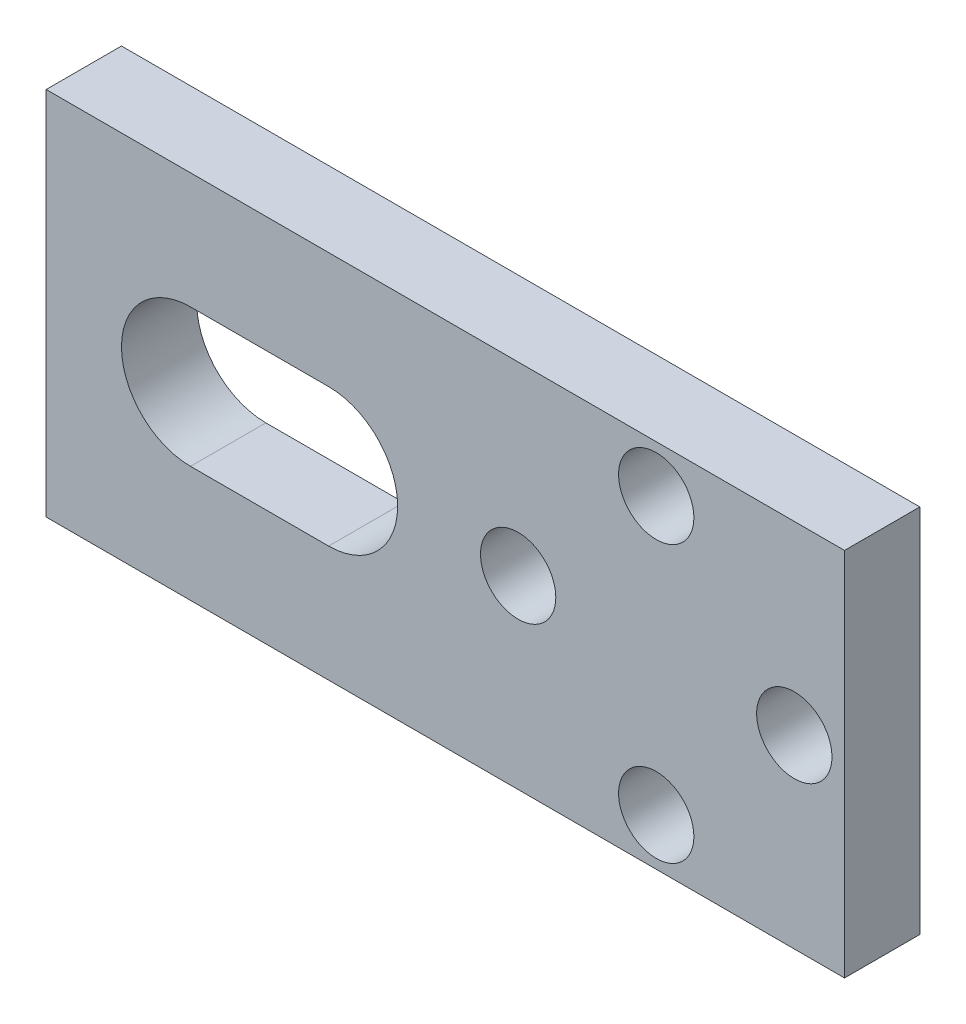
from build123d import *

# Parameters (mm, degrees)
SKETCH1_W           = 31.8
SKETCH1_H           = 14.75
SKETCH1_R           = 1.5
BOSS_EXTRUDE1_DEPTH = 3


with BuildPart() as part:
    # Sketch1 → Boss-Extrude1 (new body)
    with BuildSketch(Plane.XY):
        with Locations((15.9, 7.375)):
            Rectangle(SKETCH1_W, SKETCH1_H)
        with Locations((29.8, 7.375)):
            Circle(SKETCH1_R, mode=Mode.SUBTRACT)
        with Locations((18.8, 7.375)):
            Circle(SKETCH1_R, mode=Mode.SUBTRACT)
        with Locations((24.3, 12.875)):
            Circle(SKETCH1_R, mode=Mode.SUBTRACT)
        with Locations((24.3, 1.875)):
            Circle(SKETCH1_R, mode=Mode.SUBTRACT)
        with BuildLine():
            Line((5.75, 10.125), (11.25, 10.125))
            ThreePointArc((11.25, 10.125), (14, 7.375), (11.25, 4.625))
            Line((11.25, 4.625), (5.75, 4.625))
            ThreePointArc((5.75, 4.625), (3, 7.375), (5.75, 10.125))
        make_face(mode=Mode.SUBTRACT)
    extrude(amount=BOSS_EXTRUDE1_DEPTH)


solid = part.part
